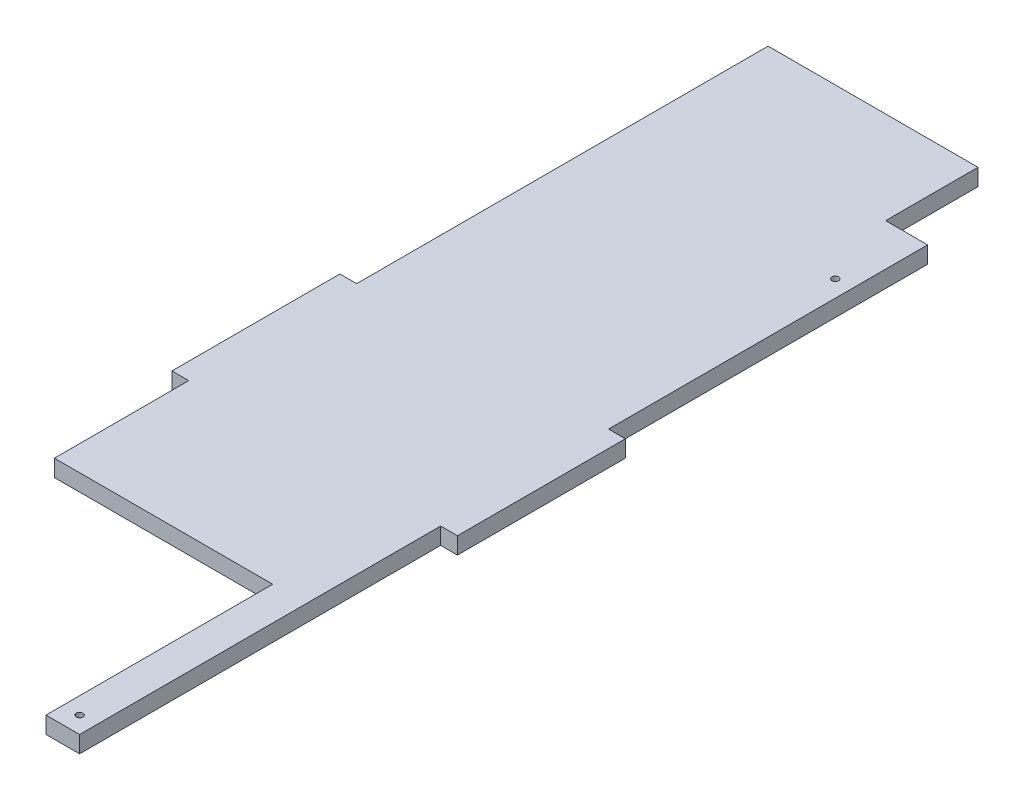
from build123d import *

# Parameters (mm, degrees)
BOSS_EXTRUDE1_DEPTH = 10
SKETCH2_R           = 2
SKETCH2_W           = 25
SKETCH2_H           = 55
CUT_EXTRUDE1_DEPTH  = 10


with BuildPart() as part:
    # Sketch1 → Boss-Extrude1 (new body)
    with BuildSketch(Plane(origin=(0, 0, 0), x_dir=(1, 0, 0), z_dir=(0, 1, 0))):
        Polygon((-75, 215), (-75, 135), (55, 135), (55, 0), (75, 0), (75, 215), (85, 215), (85, 315), (75, 315), (75, 560), (-75, 560), (-75, 315), (-85, 315), (-85, 215), align=None)
    extrude(amount=BOSS_EXTRUDE1_DEPTH)

    # Sketch2 → Cut-Extrude1 (cut)
    with BuildSketch(Plane(origin=(0, 10, 0), x_dir=(1, 0, 0), z_dir=(0, 1, 0))):
        with Locations((65, 10)):
            Circle(SKETCH2_R)
        with Locations((65, 460)):
            Circle(SKETCH2_R)
        with Locations((62.5, 532.5)):
            Rectangle(SKETCH2_W, SKETCH2_H)
    extrude(amount=-CUT_EXTRUDE1_DEPTH, mode=Mode.SUBTRACT)


solid = part.part
